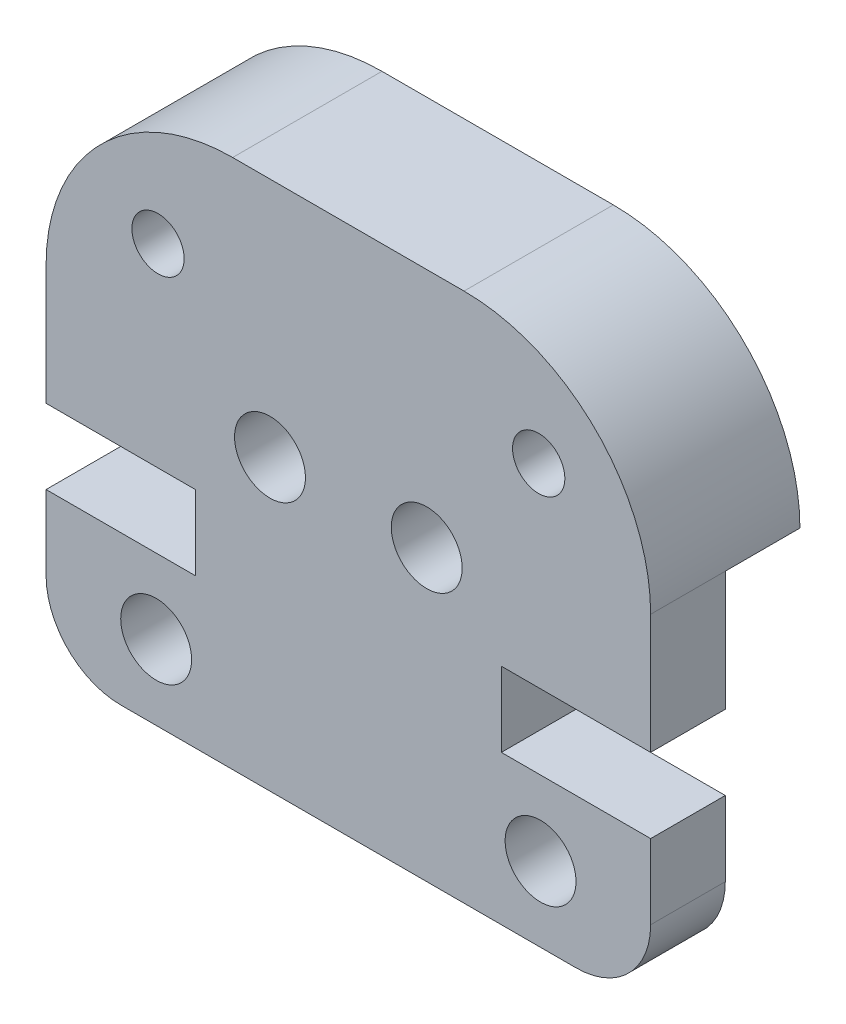
from build123d import *

# Parameters (mm, degrees)
SKETCH1_R           = 0.95
SKETCH1_R_2         = 0.7
BOSS_EXTRUDE1_DEPTH = 4
SKETCH2_W           = 16.2
SKETCH2_H           = 9.205
CUT_EXTRUDE1_DEPTH  = 2


with BuildPart() as part:
    # Sketch1 → Boss-Extrude1 (new body)
    with BuildSketch(Plane.XY):
        with BuildLine():
            Line((12.2, 4), (16.2, 4))
            Line((16.2, 4), (16.2, 2))
            ThreePointArc((16.2, 2), (15.614213562, 0.585786438), (14.2, 0))
            Line((14.2, 0), (2, 0))
            ThreePointArc((2, 0), (0.585786438, 0.585786438), (0, 2))
            Line((0, 2), (0, 4))
            Line((0, 4), (4, 4))
            Line((4, 4), (4, 6))
            Line((4, 6), (0, 6))
            Line((0, 6), (0, 9.205))
            ThreePointArc((0, 9.205), (1.464466094, 12.740533906), (5, 14.205))
            Line((5, 14.205), (11.2, 14.205))
            ThreePointArc((11.2, 14.205), (14.735533906, 12.740533906), (16.2, 9.205))
            Line((16.2, 9.205), (16.2, 6))
            Line((16.2, 6), (12.2, 6))
            Line((12.2, 6), (12.2, 4))
        make_face()
        with Locations((13.25, 2)):
            Circle(SKETCH1_R, mode=Mode.SUBTRACT)
        with Locations((13.2, 11.205)):
            Circle(SKETCH1_R_2, mode=Mode.SUBTRACT)
        with Locations((10.2, 7.75)):
            Circle(SKETCH1_R, mode=Mode.SUBTRACT)
        with Locations((6, 7.75)):
            Circle(SKETCH1_R, mode=Mode.SUBTRACT)
        with Locations((3, 11.205)):
            Circle(SKETCH1_R_2, mode=Mode.SUBTRACT)
        with Locations((2.95, 2)):
            Circle(SKETCH1_R, mode=Mode.SUBTRACT)
    extrude(amount=BOSS_EXTRUDE1_DEPTH)

    # Sketch2 → Cut-Extrude1 (cut)
    with BuildSketch(Plane(origin=(0, 0, 0), x_dir=(-1, 0, 0), z_dir=(0, 0, -1))):
        with Locations((-8.1, 4.6025)):
            Rectangle(SKETCH2_W, SKETCH2_H)
    extrude(amount=-CUT_EXTRUDE1_DEPTH, mode=Mode.SUBTRACT)


solid = part.part
